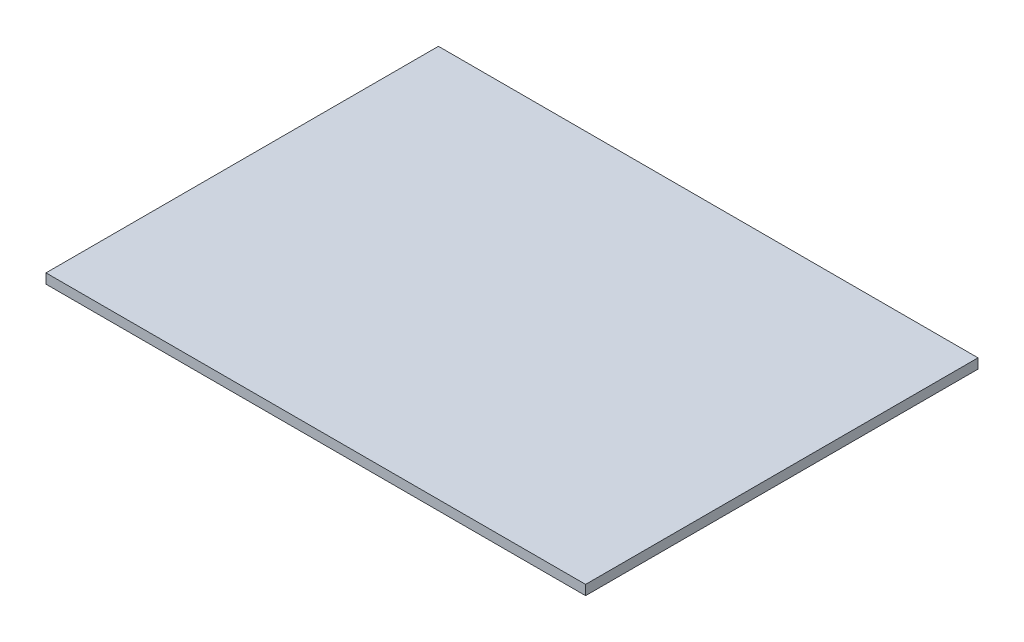
from build123d import *

# Parameters (mm, degrees)
SKETCH1_W           = 5500
SKETCH1_H           = 4000
BOSS_EXTRUDE1_DEPTH = 100


with BuildPart() as part:
    # Sketch1 → Boss-Extrude1 (new body)
    with BuildSketch(Plane(origin=(0, 0, 0), x_dir=(1, 0, 0), z_dir=(0, 1, 0))):
        with Locations((2750, 2000)):
            Rectangle(SKETCH1_W, SKETCH1_H)
    extrude(amount=BOSS_EXTRUDE1_DEPTH)


solid = part.part
